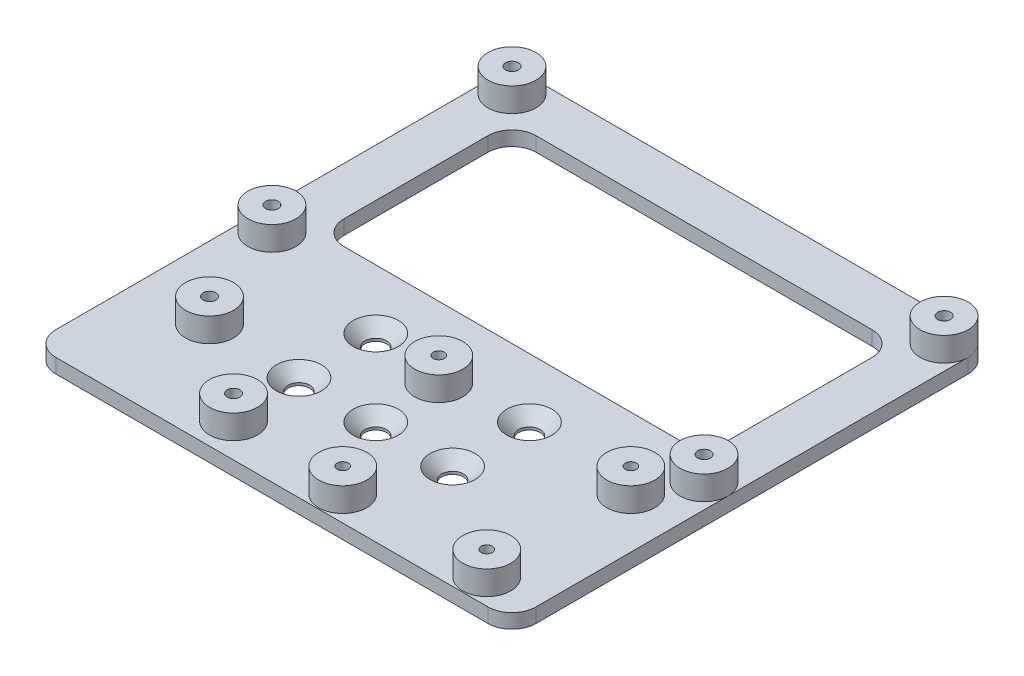
from build123d import *

# Parameters (mm, degrees)
SKETCH1_W                                    = 100
SKETCH1_H                                    = 100
BOSS_EXTRUDE1_DEPTH                          = 3
SKETCH4_R                                    = 5
BOSS_EXTRUDE2_DEPTH                          = 5
SKETCH6_R                                    = 5
BOSS_EXTRUDE3_DEPTH                          = 5
SKETCH5_R                                    = 1.325
SKETCH5_R_2                                  = 1.15
CUT_EXTRUDE1_DEPTH                           = 9
SKETCH7_W                                    = 80
SKETCH7_H                                    = 40
CUT_EXTRUDE2_DEPTH                           = 4
FILLET2_R                                    = 5
CSK_FOR_M4_COUNTERSUNK_FLAT_HEAD_SCR_2_COUNT = 2
CSK_FOR_M4_COUNTERSUNK_FLAT_HEAD_SCR_2_PITCH = 16
CSK_FOR_M4_COUNTERSUNK_FLAT_HEAD_SCR_3_COUNT = 2
CSK_FOR_M4_COUNTERSUNK_FLAT_HEAD_SCR_3_PITCH = 22.627416998
CSK_FOR_M4_COUNTERSUNK_FLAT_HEAD_SCR_4_COUNT = 2
CSK_FOR_M4_COUNTERSUNK_FLAT_HEAD_SCR_4_PITCH = 35.77708764
CSK_FOR_M4_COUNTERSUNK_FLAT_HEAD_SCR_5_COUNT = 2
CSK_FOR_M4_COUNTERSUNK_FLAT_HEAD_SCR_5_PITCH = 32


with BuildPart() as part:
    # Sketch1 → Boss-Extrude1 (new body)
    with BuildSketch(Plane(origin=(0, 0, 0), x_dir=(1, 0, 0), z_dir=(0, 1, 0))):
        Rectangle(SKETCH1_W, SKETCH1_H)
    extrude(amount=BOSS_EXTRUDE1_DEPTH)

    # Sketch4 → Boss-Extrude2 (add)
    with BuildSketch(Plane(origin=(0, 3, 0), x_dir=(1, 0, 0), z_dir=(0, 1, 0))):
        with Locations((-45, 45)):
            Circle(SKETCH4_R)
        with Locations((-45, -5)):
            Circle(SKETCH4_R)
        with Locations((45, -5)):
            Circle(SKETCH4_R)
        with Locations((45, 45)):
            Circle(SKETCH4_R)
    extrude(amount=BOSS_EXTRUDE2_DEPTH)

    # Sketch6 → Boss-Extrude3 (add)
    with BuildSketch(Plane(origin=(0, 3, 0), x_dir=(1, 0, 0), z_dir=(0, 1, 0))):
        with Locations((39.5, -44.75)):
            Circle(SKETCH6_R)
        with Locations((39.5, -14.75)):
            Circle(SKETCH6_R)
        with Locations((9.5, -44.75)):
            Circle(SKETCH6_R)
        with Locations((-0.5, -14.75)):
            Circle(SKETCH6_R)
        with Locations((-35, -28)):
            Circle(SKETCH6_R)
        with Locations((-15, -43)):
            Circle(SKETCH6_R)
    extrude(amount=BOSS_EXTRUDE3_DEPTH)

    # Sketch5 → Cut-Extrude1 (cut, through all)
    with BuildSketch(Plane(origin=(0, 8, 0), x_dir=(1, 0, 0), z_dir=(0, 1, 0))):
        with Locations((-45, 45)):
            Circle(SKETCH5_R)
        with Locations((45, 45)):
            Circle(SKETCH5_R)
        with Locations((45, -5)):
            Circle(SKETCH5_R)
        with Locations((-45, -5)):
            Circle(SKETCH5_R)
        with Locations((39.5, -14.75)):
            Circle(SKETCH5_R_2)
        with Locations((39.5, -44.75)):
            Circle(SKETCH5_R_2)
        with Locations((9.5, -44.75)):
            Circle(SKETCH5_R_2)
        with Locations((-0.5, -14.75)):
            Circle(SKETCH5_R_2)
        with Locations((-35, -28)):
            Circle(SKETCH5_R)
        with Locations((-15, -43)):
            Circle(SKETCH5_R)
    extrude(amount=-CUT_EXTRUDE1_DEPTH, mode=Mode.SUBTRACT)

    # Sketch7 → Cut-Extrude2 (cut, through all)
    with BuildSketch(Plane(origin=(0, 3, 0), x_dir=(1, 0, 0), z_dir=(0, 1, 0))):
        with Locations((0, 20)):
            Rectangle(SKETCH7_W, SKETCH7_H)
    extrude(amount=-CUT_EXTRUDE2_DEPTH, mode=Mode.SUBTRACT)

    # Fillet2
    fillet2_edges = [part.edges().sort_by_distance(p)[0] for p in [
        (50, 1.5, -50),
        (-50, 1.5, -50),
        (-50, 1.5, 50),
        (50, 1.5, 50),
        (40, 1.5, 0),
        (40, 1.5, -40),
        (-40, 1.5, -40),
        (-40, 1.5, 0),
    ]]
    fillet(fillet2_edges, radius=FILLET2_R)

    # Sketch11 → CSK for M4 Countersunk Flat Head Screw1 (revolve, cut)
    with BuildSketch(Plane(origin=(-16, 3, 12.372677549), x_dir=(0, 0, 1), z_dir=(1, 0, 0))):
        Polygon((0, 0), (0, 3), (2.25, 3), (2.25, 2.45), (4.7, 0), align=None)
    csk_for_m4_countersunk_flat_head_screw1 = revolve(axis=Axis((-16, 9.35, 12.372677549), (0, -1, 0)), mode=Mode.SUBTRACT)

    # CSK for M4 Countersunk Flat Head Scr 2: CSK for M4 Countersunk Flat Head Screw1 ×2
    with Locations(*[(0, 0, i * CSK_FOR_M4_COUNTERSUNK_FLAT_HEAD_SCR_2_PITCH) for i in range(1, CSK_FOR_M4_COUNTERSUNK_FLAT_HEAD_SCR_2_COUNT)]):
        add(csk_for_m4_countersunk_flat_head_screw1, mode=Mode.SUBTRACT)

    # CSK for M4 Countersunk Flat Head Scr 3: CSK for M4 Countersunk Flat Head Screw1 ×2
    with Locations(*[Vector(0.707106781, 0, 0.707106781) * (i * CSK_FOR_M4_COUNTERSUNK_FLAT_HEAD_SCR_3_PITCH) for i in range(1, CSK_FOR_M4_COUNTERSUNK_FLAT_HEAD_SCR_3_COUNT)]):
        add(csk_for_m4_countersunk_flat_head_screw1, mode=Mode.SUBTRACT)

    # CSK for M4 Countersunk Flat Head Scr 4: CSK for M4 Countersunk Flat Head Screw1 ×2
    with Locations(*[Vector(0.894427191, 0, 0.447213595) * (i * CSK_FOR_M4_COUNTERSUNK_FLAT_HEAD_SCR_4_PITCH) for i in range(1, CSK_FOR_M4_COUNTERSUNK_FLAT_HEAD_SCR_4_COUNT)]):
        add(csk_for_m4_countersunk_flat_head_screw1, mode=Mode.SUBTRACT)

    # CSK for M4 Countersunk Flat Head Scr 5: CSK for M4 Countersunk Flat Head Screw1 ×2
    with Locations(*[(i * CSK_FOR_M4_COUNTERSUNK_FLAT_HEAD_SCR_5_PITCH, 0, 0) for i in range(1, CSK_FOR_M4_COUNTERSUNK_FLAT_HEAD_SCR_5_COUNT)]):
        add(csk_for_m4_countersunk_flat_head_screw1, mode=Mode.SUBTRACT)


solid = part.part
